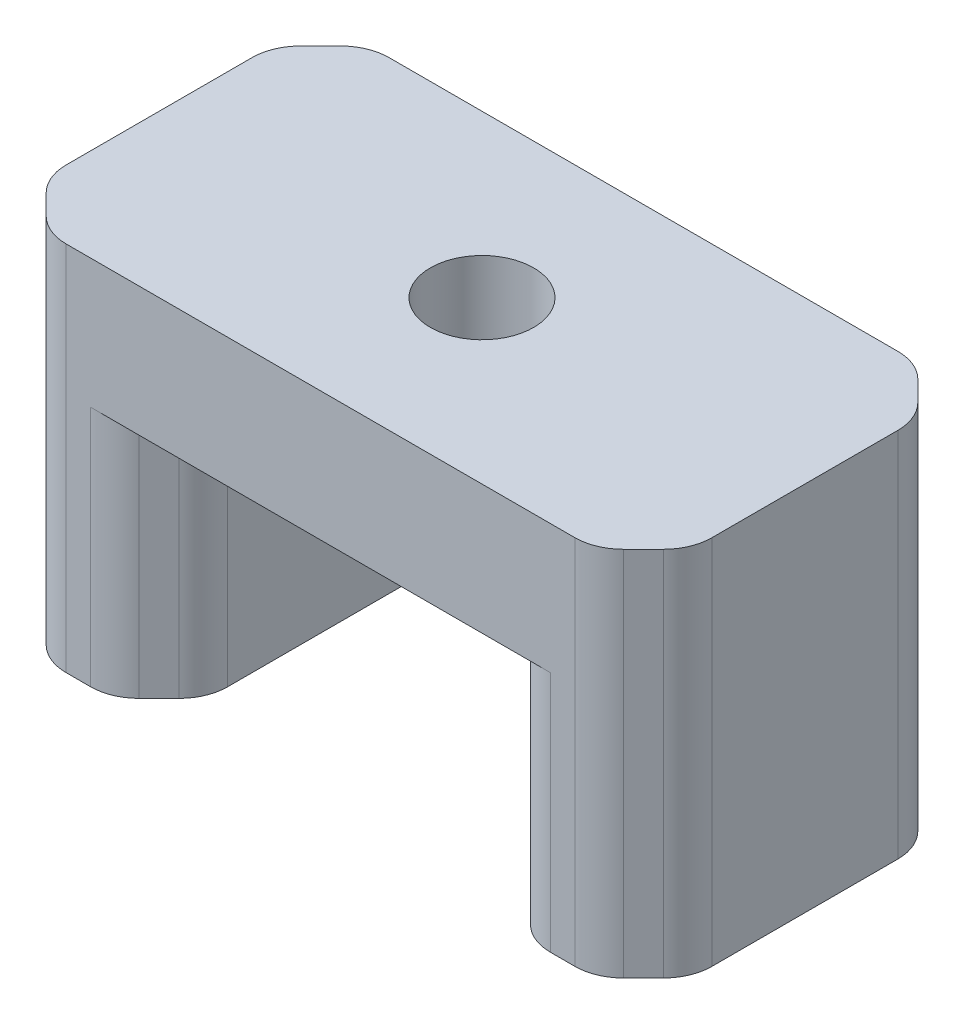
from build123d import *

# Parameters (mm, degrees)
ESQUISSE1_W             = 10
ESQUISSE1_H             = 20
BOSS_EXTRU_1_DEPTH      = 15
BOSS_EXTRU_1_2_DEPTH    = 15
ESQUISSE3_W             = 40
ESQUISSE3_H             = 20
BOSS_EXTRU_2_DEPTH      = 8
ESQUISSE4_R             = 3.2
ENL_V_MAT_EXTRU_1_DEPTH = 10
ESQUISSE1_3_R           = 2.75
ENL_V_MAT_EXTRU_3_DEPTH = 7
ESQUISSE1_4_R           = 3.5
ESQUISSE1_4_R_2         = 2.75
ENL_V_MAT_EXTRU_4_DEPTH = 1
CHANFREIN1_SIZE         = 3
CONG_1_R                = 3


with BuildPart() as part:
    # Esquisse1 → Boss.-Extru.1 (new body)
    with BuildSketch(Plane(origin=(0, 0, 0), x_dir=(1, 0, 0), z_dir=(0, 1, 0))):
        with Locations((-15, 0)):
            Rectangle(ESQUISSE1_W, ESQUISSE1_H)
    extrude(amount=BOSS_EXTRU_1_DEPTH)



with BuildPart() as body_2:
    # Esquisse1 → Boss.-Extru.1 2 (new body)
    with BuildSketch(Plane(origin=(0, 0, 0), x_dir=(1, 0, 0), z_dir=(0, 1, 0))):
        with Locations((15, 0)):
            Rectangle(ESQUISSE1_W, ESQUISSE1_H)
    extrude(amount=BOSS_EXTRU_1_2_DEPTH)


with BuildPart() as part_1:
    add(part.part)

    add(body_2.part)  # Boss.-Extru.2 merges body 2
    # Esquisse3 → Boss.-Extru.2 (add)
    with BuildSketch(Plane(origin=(0, 15, 0), x_dir=(1, 0, 0), z_dir=(0, 1, 0))):
        Rectangle(ESQUISSE3_W, ESQUISSE3_H)
    extrude(amount=BOSS_EXTRU_2_DEPTH)

    # Esquisse4 → Enl_v. mat.-Extru.1 (cut)
    with BuildSketch(Plane(origin=(0, 23, 0), x_dir=(1, 0, 0), z_dir=(0, 1, 0))):
        Circle(ESQUISSE4_R)
    extrude(amount=-ENL_V_MAT_EXTRU_1_DEPTH, mode=Mode.SUBTRACT)

    # Esquisse1_3 → Enl_v. mat.-Extru.3 (cut)
    with BuildSketch(Plane(origin=(0, 0, 0), x_dir=(1, 0, 0), z_dir=(0, 1, 0))):
        with Locations((-15, 0)):
            Circle(ESQUISSE1_3_R)
        with Locations((15, 0)):
            Circle(ESQUISSE1_3_R)
    extrude(amount=ENL_V_MAT_EXTRU_3_DEPTH, mode=Mode.SUBTRACT)

    # Esquisse1_4 → Enl_v. mat.-Extru.4 (cut)
    # profile 1 of 2: a face of its own
    with BuildSketch(Plane(origin=(0, 0, 0), x_dir=(1, 0, 0), z_dir=(0, 1, 0))):
        with Locations((-15, 0)):
            Circle(ESQUISSE1_4_R)
        with Locations((-15, 0)):
            Circle(ESQUISSE1_4_R_2, mode=Mode.SUBTRACT)
    # profile 2 of 2: a face of its own
    with BuildSketch(Plane(origin=(0, 0, 0), x_dir=(1, 0, 0), z_dir=(0, 1, 0))):
        with Locations((15, 0)):
            Circle(ESQUISSE1_4_R)
        with Locations((15, 0)):
            Circle(ESQUISSE1_4_R_2, mode=Mode.SUBTRACT)
    extrude(amount=ENL_V_MAT_EXTRU_4_DEPTH, mode=Mode.SUBTRACT)

    # Chanfrein1
    chanfrein1_edges = [part_1.edges().sort_by_distance(p)[0] for p in [
        (10, 7.5, -10),
        (20, 11.5, -10),
        (10, 7.5, 10),
        (-10, 7.5, -10),
        (-10, 7.5, 10),
        (20, 11.5, 10),
        (-20, 11.5, -10),
        (-20, 11.5, 10),
    ]]
    chamfer(chanfrein1_edges, length=CHANFREIN1_SIZE)

    # Cong_1
    cong_1_edges = [part_1.edges().sort_by_distance(p)[0] for p in [
        (-10, 7.5, -7),
        (-13, 7.5, -10),
        (10, 7.5, -7),
        (13, 7.5, -10),
        (13, 7.5, 10),
        (17, 11.5, 10),
        (20, 11.5, 7),
        (20, 11.5, -7),
        (17, 11.5, -10),
        (-17, 11.5, -10),
        (-20, 11.5, -7),
        (-20, 11.5, 7),
        (-17, 11.5, 10),
        (-10, 7.5, 7),
        (-13, 7.5, 10),
        (10, 7.5, 7),
    ]]
    fillet(cong_1_edges, radius=CONG_1_R)


solid = part_1.part
